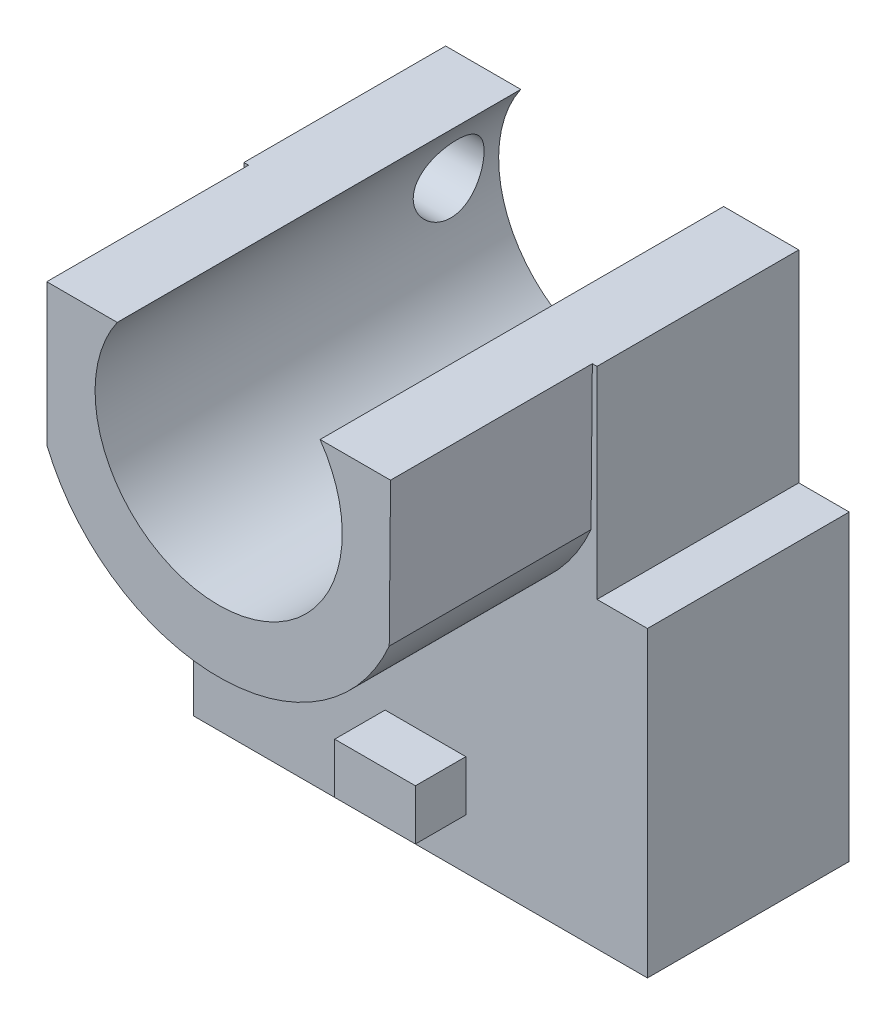
from build123d import *

# Parameters (mm, degrees)
BOSS_EXTRUDE1_DEPTH     = 20
SKETCH2_W               = 8
SKETCH2_H               = 5
BOSS_EXTRUDE2_DEPTH     = 5
SKETCH3_R               = 12.25
CUT_EXTRUDE1_DEPTH      = 20
BOSS_EXTRUDE3_DEPTH     = 20
SKETCH6_R               = 3.5
CUT_EXTRUDE2_DEPTH      = 1
CUT_EXTRUDE2_DEPTH_BACK = 8


with BuildPart() as part:
    # Sketch1 → Boss-Extrude1 (new body)
    with BuildSketch(Plane.XY):
        Polygon((17.5, 15), (22.5, 15), (22.5, -15), (-22.5, -15), (-22.5, 15), (-17.5, 15), (-17.5, 35), (17.5, 35), align=None)
    extrude(amount=BOSS_EXTRUDE1_DEPTH)

    # Sketch2 → Boss-Extrude2 (add)
    with BuildSketch(Plane.XY.offset(20)):
        with Locations((0.5, -7.5)):
            Rectangle(SKETCH2_W, SKETCH2_H)
    extrude(amount=BOSS_EXTRUDE2_DEPTH)

    # Sketch3 → Cut-Extrude1 (cut)
    with BuildSketch(Plane.XY.offset(20)):
        with Locations((0, 28)):
            Circle(SKETCH3_R)
    extrude(amount=-CUT_EXTRUDE1_DEPTH, mode=Mode.SUBTRACT)

    # Sketch4 → Boss-Extrude3 (add)
    with BuildSketch(Plane.XY.offset(20)):
        with BuildLine():
            Line((-17.036725037, 35), (-17.036725037, 21))
            ThreePointArc((-17.036725037, 21), (-0.167488081, 9.582021073), (16.906605879, 20.691328599))
            Line((16.906605879, 20.691328599), (17.036725037, 35))
            Line((17.036725037, 35), (10.052984631, 35))
            ThreePointArc((10.052984631, 35), (0, 15.75), (-10.052984631, 35))
            Line((-10.052984631, 35), (-17.036725037, 35))
        make_face()
    extrude(amount=BOSS_EXTRUDE3_DEPTH)

    # Sketch6 → Cut-Extrude2 (cut, two sides)
    with BuildSketch(Plane.ZY.offset(17.5)) as cut_extrude2_sk:
        with Locations((5, 29)):
            Circle(SKETCH6_R)
    extrude(amount=CUT_EXTRUDE2_DEPTH, mode=Mode.SUBTRACT)
    extrude(cut_extrude2_sk.sketch, amount=-CUT_EXTRUDE2_DEPTH_BACK, mode=Mode.SUBTRACT)


solid = part.part
